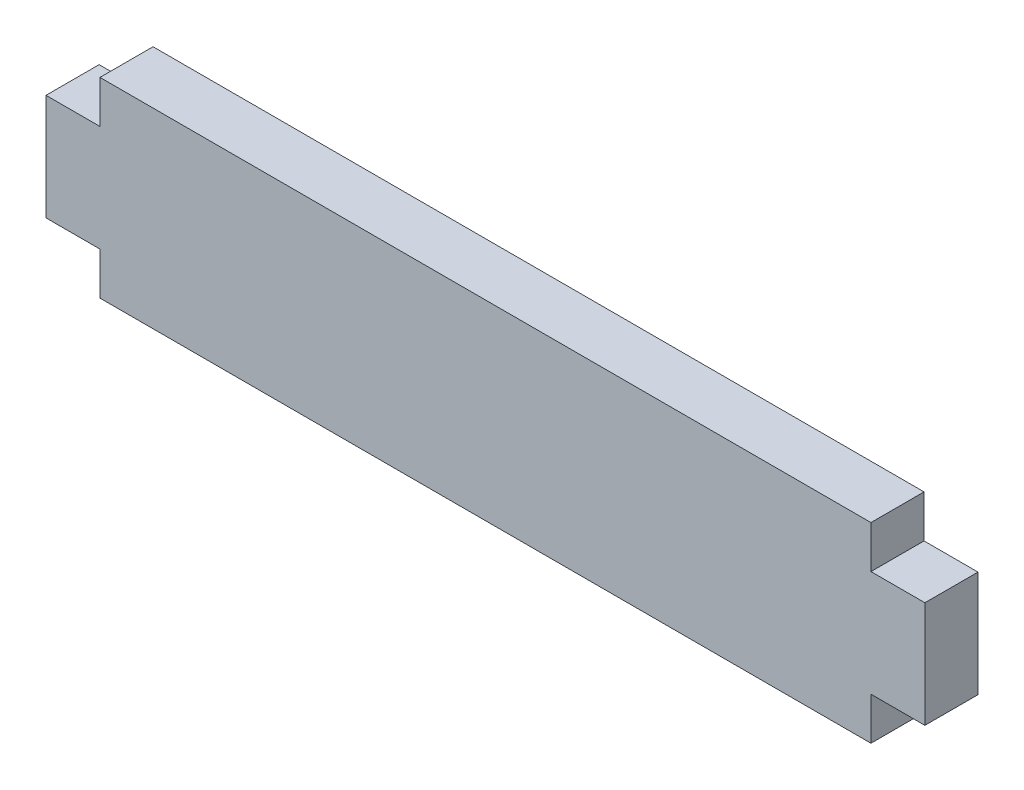
from build123d import *

# Parameters (mm, degrees)
BOSS_EXTRUDE1_DEPTH = 3.175


with BuildPart() as part:
    # Sketch1 → Boss-Extrude1 (new body)
    with BuildSketch(Plane.XY):
        Polygon((-23.0505, 3.175), (-26.2763, 3.175), (-26.2763, -3.175), (-23.0505, -3.175), (-23.0505, -5.715), (23.0505, -5.715), (23.0505, -3.175), (26.2763, -3.175), (26.2763, 3.175), (23.0505, 3.175), (23.0505, 5.715), (-23.0505, 5.715), align=None)
    extrude(amount=BOSS_EXTRUDE1_DEPTH)


solid = part.part
